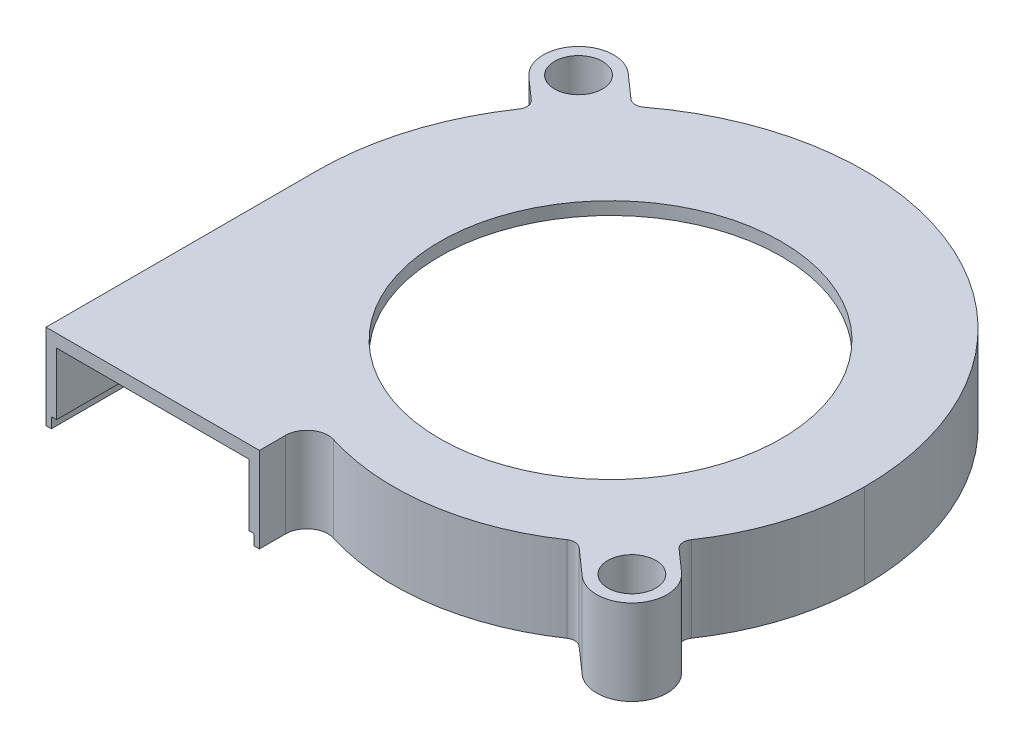
from build123d import *

# Parameters (mm, degrees)
SKETCH_1_R          = 16
SKETCH_1_R_2        = 2.25
EXTRUDE_1_DEPTH     = 8
CUT_EXTRUDE_1_DEPTH = 6.8
CUT_EXTRUDE_8_DEPTH = 1


with BuildPart() as part:
    # Эскиз1 → Бобышка-Вытянуть1 (new body)
    with BuildSketch(Plane(origin=(0, 0, 0), x_dir=(1, 0, 0), z_dir=(0, 1, 0))):
        with BuildLine():
            Line((-27.5, -25.4), (-7.5, -25.4))
            Line((-7.5, -25.4), (-7.5, -22.955849111))
            ThreePointArc((-7.5, -22.955849111), (-6.68281162, -21.343100938), (-4.899043329, -21.048271831))
            ThreePointArc((-4.899043329, -21.048271831), (4.948796089, -21.832347138), (14.151976117, -18.241220202))
            ThreePointArc((14.151976117, -18.241220202), (14.777726241, -18.069792078), (15.376980036, -18.318480053))
            Line((15.376980036, -18.318480053), (17.814747272, -20.472785982))
            ThreePointArc((17.814747272, -20.472785982), (22.472785982, -20.185252728), (22.185252728, -15.527214018))
            Line((22.185252728, -15.527214018), (20.143734708, -13.723081814))
            ThreePointArc((20.143734708, -13.723081814), (19.813719174, -13.098302749), (19.979075206, -12.411340949))
            ThreePointArc((19.979075206, -12.411340949), (22.823148445, -6.493089604), (23.8, 0))
            ThreePointArc((23.8, 0), (9.576401492, 22.98111988), (-17.333078903, 20.466663618))
            ThreePointArc((-17.333078903, 20.466663618), (-17.974550182, 20.264645495), (-18.598905377, 20.514600122))
            Line((-18.598905377, 20.514600122), (-20.814747272, 22.472785982))
            ThreePointArc((-20.814747272, 22.472785982), (-25.472785982, 22.185252728), (-25.185252728, 17.527214018))
            Line((-25.185252728, 17.527214018), (-23.20688118, 15.778885673))
            ThreePointArc((-23.20688118, 15.778885673), (-22.876796583, 15.153555184), (-23.04284729, 14.466226133))
            ThreePointArc((-23.04284729, 14.466226133), (-26.362874376, 7.569397218), (-27.5, 0))
            Line((-27.5, 0), (-27.5, -25.4))
        make_face()
        Circle(SKETCH_1_R, mode=Mode.SUBTRACT)
        with Locations((-23, 20)):
            Circle(SKETCH_1_R_2, mode=Mode.SUBTRACT)
        with Locations((20, -18)):
            Circle(SKETCH_1_R_2, mode=Mode.SUBTRACT)
    extrude(amount=-EXTRUDE_1_DEPTH)

    # Эскиз2 → Вырез-Вытянуть1 (cut)
    with BuildSketch(Plane(origin=(0, -8, 0), x_dir=(-1, 0, 0), z_dir=(0, -1, 0))):
        with BuildLine():
            Line((8.5, -25.4), (8.5, -22.955849111))
            ThreePointArc((8.5, -22.955849111), (7.274217431, -20.536726851), (4.598564994, -20.094483191))
            ThreePointArc((4.598564994, -20.094483191), (-4.803026036, -20.843028639), (-13.589169994, -17.414631267))
            ThreePointArc((-13.589169994, -17.414631267), (-16.632858543, -14.893819788), (-19.152217909, -11.84892917))
            ThreePointArc((-19.152217909, -11.84892917), (-21.867461922, -6.198703298), (-22.799999997, 0.000326884))
            ThreePointArc((-22.799999997, 0.000326884), (-9.131074658, 22.085751778), (16.729450225, 19.669398029))
            ThreePointArc((16.729450225, 19.669398029), (19.707335368, 17.009099388), (22.216615604, 13.902895678))
            ThreePointArc((22.216615604, 13.902895678), (25.407255273, 7.274792502), (26.500000107, 0.000327424))
            Line((26.500000107, 0.000327424), (26.5, -25.4))
            Line((26.5, -25.4), (8.5, -25.4))
        make_face()
    extrude(amount=-CUT_EXTRUDE_1_DEPTH, mode=Mode.SUBTRACT)

    # Эскиз11 → Вырез-Вытянуть8 (cut)
    with BuildSketch(Plane.XZ.offset(8)):
        with BuildLine():
            Line((-8.5, 22.955849111), (-8.5, 25.4))
            Line((-8.5, 25.4), (-8, 25.4))
            Line((-8, 25.4), (-8, 22.955849111))
            ThreePointArc((-8, 22.955849111), (-6.978514526, 20.939913894), (-4.748804162, 20.571377511))
            ThreePointArc((-4.748804162, 20.571377511), (14.487462515, 17.39189423), (23.3, -0.000122694))
            ThreePointArc((23.3, -0.000122694), (-1.849981151, -25.16680236), (-26.999999983, -0.000160392))
            Line((-26.999999983, -0.000160392), (-27.000000053, 25.4))
            Line((-27.000000053, 25.4), (-26.500000054, 25.4))
            Line((-26.500000054, 25.4), (-26.500000053, -0.000327424))
            ThreePointArc((-26.500000053, -0.000327424), (-1.849999809, -24.666802429), (22.799999998, -0.000327043))
            ThreePointArc((22.799999998, -0.000327043), (14.191842001, 16.98864676), (-4.598564994, 20.094483191))
            ThreePointArc((-4.598564994, 20.094483191), (-7.274217431, 20.536726851), (-8.5, 22.955849111))
        make_face()
    extrude(amount=-CUT_EXTRUDE_8_DEPTH, mode=Mode.SUBTRACT)


solid = part.part
